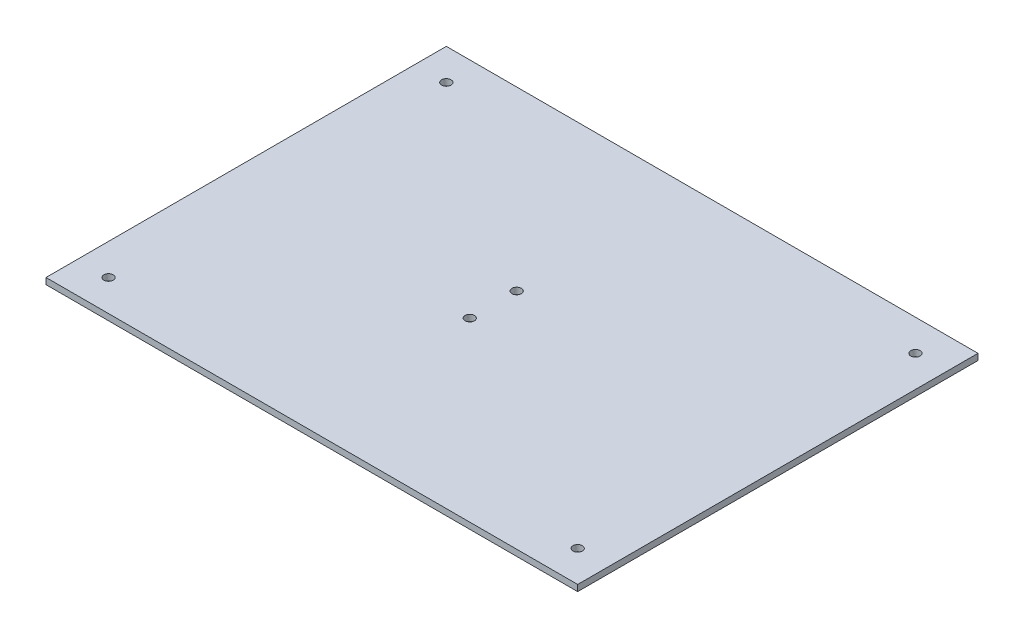
from build123d import *

# Parameters (mm, degrees)
SKETCH_1_W          = 170
SKETCH_1_H          = 128
SKETCH_1_R          = 1.5
EXTRUDE_1_DEPTH     = 2
SKETCH_2_R          = 1.5
CUT_EXTRUDE_1_DEPTH = 3


with BuildPart() as part:
    # Эскиз1 → Бобышка-Вытянуть1 (new body)
    with BuildSketch(Plane(origin=(0, 0, 0), x_dir=(1, 0, 0), z_dir=(0, 1, 0))):
        with Locations((10.64154107, -10.35845893)):
            Rectangle(SKETCH_1_W, SKETCH_1_H)
        with Locations((-64.35845893, 43.64154107)):
            Circle(SKETCH_1_R, mode=Mode.SUBTRACT)
        with Locations((85.64154107, 43.64154107)):
            Circle(SKETCH_1_R, mode=Mode.SUBTRACT)
        with Locations((85.64154107, -64.35845893)):
            Circle(SKETCH_1_R, mode=Mode.SUBTRACT)
        with Locations((-64.35845893, -64.35845893)):
            Circle(SKETCH_1_R, mode=Mode.SUBTRACT)
    extrude(amount=EXTRUDE_1_DEPTH)

    # Эскиз2 → Вырез-Вытянуть1 (cut, through all)
    with BuildSketch(Plane(origin=(0, 2, 0), x_dir=(1, 0, 0), z_dir=(0, 1, 0))):
        with Locations((4.64154107, -17.85845893)):
            Circle(SKETCH_2_R)
        with Locations((4.64154107, -2.85845893)):
            Circle(SKETCH_2_R)
    extrude(amount=-CUT_EXTRUDE_1_DEPTH, mode=Mode.SUBTRACT)


solid = part.part
